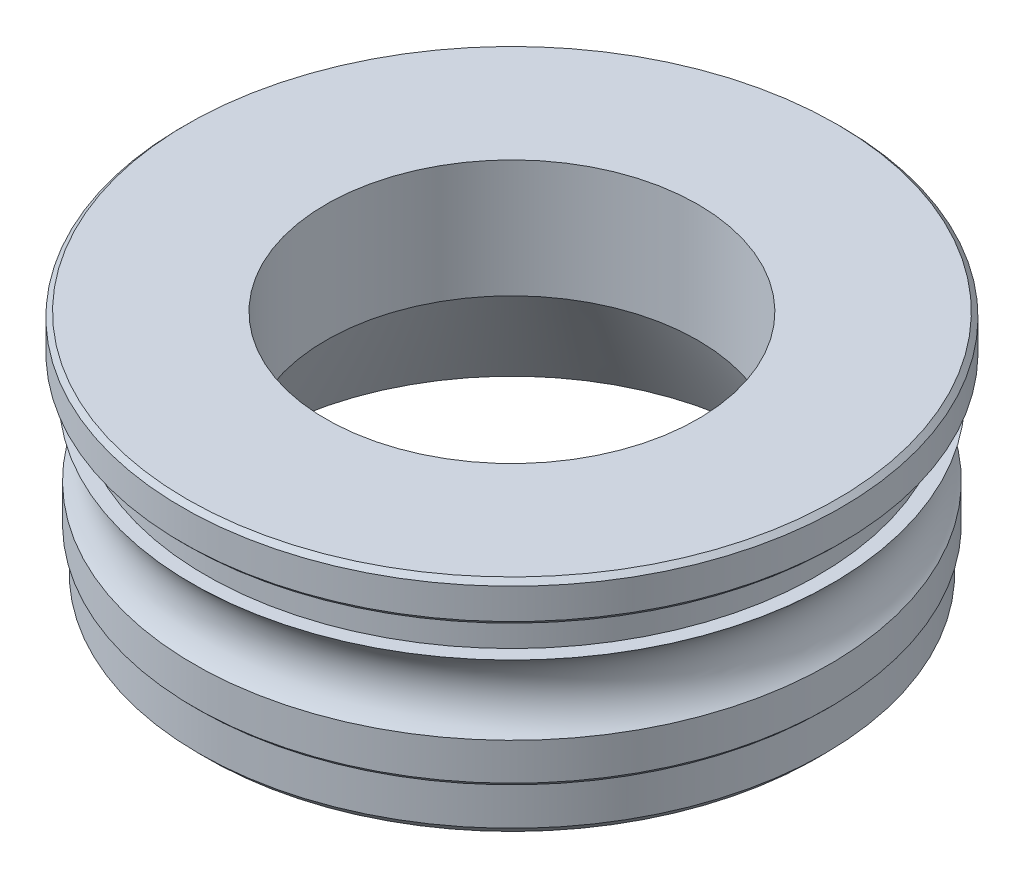
from build123d import *


with BuildPart() as part:
    # Croquis1 → Revolución1 (revolve)
    with BuildSketch(Plane.XY):
        with BuildLine():
            Line((6.45, 0), (6.65, 0.2))
            Line((6.65, 0.2), (6.65, 1))
            Line((6.65, 1), (6.75, 1.1))
            Line((6.75, 1.1), (6.75, 1.767))
            Line((6.75, 1.767), (6.75, 1.889))
            ThreePointArc((6.75, 1.889), (6.429860393, 2.6559209), (6.8, 3.4))
            Line((6.8, 3.4), (6.5, 3.4))
            Line((6.5, 3.4), (6.5, 4.15))
            Line((6.5, 4.15), (6.9, 4.15))
            Line((6.9, 4.15), (7, 4.25))
            Line((7, 4.25), (7, 4.9))
            Line((7, 4.9), (6.9, 5))
            Line((6.9, 5), (3.95, 5))
            Line((3.95, 5), (3.95, 2.5))
            Line((3.95, 2.5), (5.393375673, 0))
            Line((5.393375673, 0), (6.45, 0))
        make_face()
    revolve(axis=Axis((0, 0, 0), (0, 1, 0)))


solid = part.part
